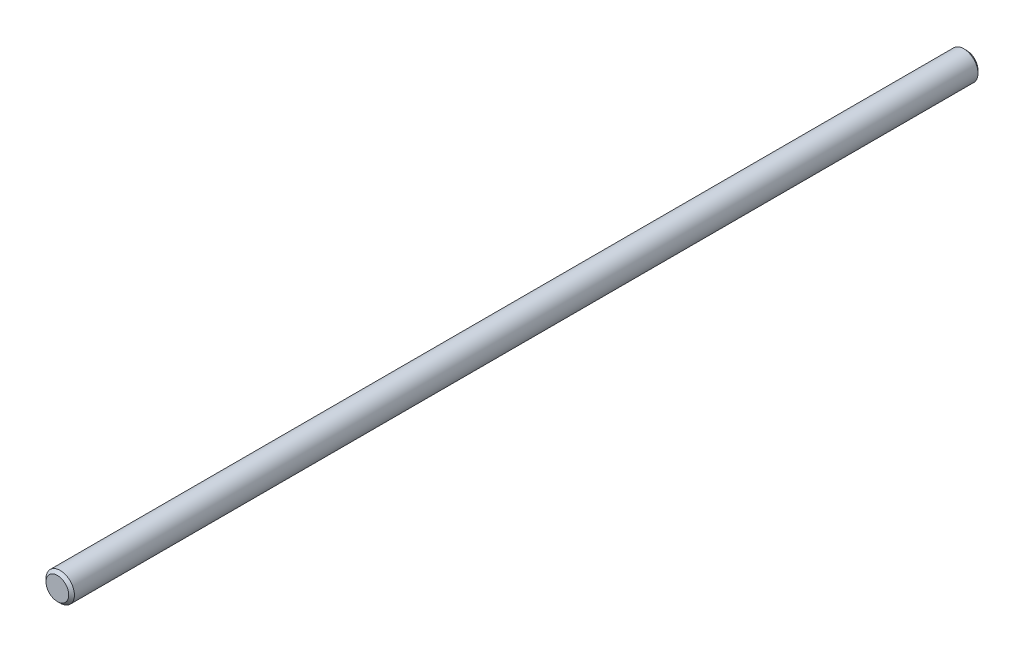
from build123d import *

# Parameters (mm, degrees)
SKETCH1_R      = 4.7625
EXTRUDE1_DEPTH = 152.4
CHAMFER1_SIZE  = 0.9525


with BuildPart() as part:
    # Sketch1 → Extrude1 (new body, symmetric)
    with BuildSketch(Plane.XY):
        Circle(SKETCH1_R)
    extrude(amount=EXTRUDE1_DEPTH, both=True)

    # Chamfer1
    chamfer1_edges = [part.edges().sort_by_distance(p)[0] for p in [
        (-4.7625, 0, -152.4),
        (-4.7625, 0, 152.4),
    ]]
    chamfer(chamfer1_edges, length=CHAMFER1_SIZE)


solid = part.part
